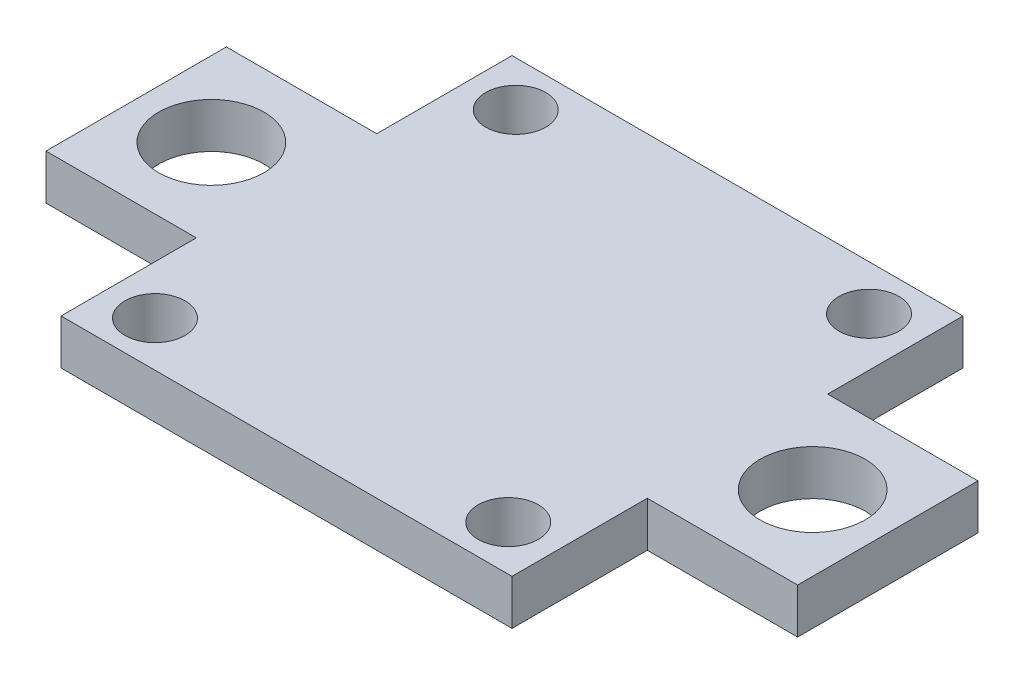
from build123d import *

# Parameters (mm, degrees)
BOSS_EXTRUDE1_DEPTH = 3
SKETCH2_R           = 3.5
SKETCH2_R_2         = 2
CUT_EXTRUDE1_DEPTH  = 4


with BuildPart() as part:
    # Sketch1 → Boss-Extrude1 (new body)
    with BuildSketch(Plane(origin=(0, 0, 0), x_dir=(1, 0, 0), z_dir=(0, 1, 0))):
        Polygon((-15, -6), (-15, -15), (15, -15), (15, -6), (25, -6), (25, 6), (15, 6), (15, 15), (-15, 15), (-15, 6), (-25, 6), (-25, -6), align=None)
    extrude(amount=BOSS_EXTRUDE1_DEPTH)

    # Sketch2 → Cut-Extrude1 (cut, through all)
    with BuildSketch(Plane(origin=(0, 3, 0), x_dir=(1, 0, 0), z_dir=(0, 1, 0))):
        with Locations((-20, 0)):
            Circle(SKETCH2_R)
        with Locations((-11.75, 12)):
            Circle(SKETCH2_R_2)
        with Locations((-11.75, -12)):
            Circle(SKETCH2_R_2)
        with Locations((11.75, -12)):
            Circle(SKETCH2_R_2)
        with Locations((20, 0)):
            Circle(SKETCH2_R)
        with Locations((11.75, 12)):
            Circle(SKETCH2_R_2)
    extrude(amount=-CUT_EXTRUDE1_DEPTH, mode=Mode.SUBTRACT)


solid = part.part
